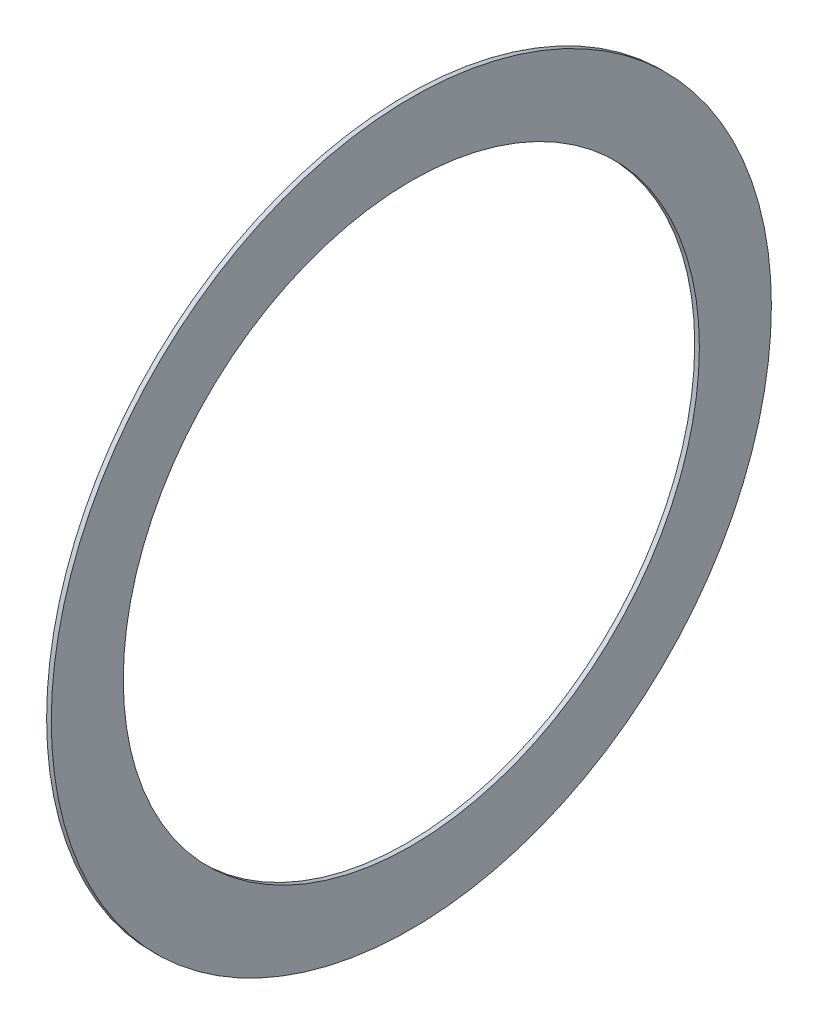
from build123d import *

# Parameters (mm, degrees)
SKETCH1_R           = 155
SKETCH1_R_2         = 124
BOSS_EXTRUDE1_DEPTH = 2


with BuildPart() as part:
    # Sketch1 → Boss-Extrude1 (new body)
    with BuildSketch(Plane(origin=(0, 0, 0), x_dir=(0, 0, -1), z_dir=(1, 0, 0))):
        Circle(SKETCH1_R)
        Circle(SKETCH1_R_2, mode=Mode.SUBTRACT)
    extrude(amount=BOSS_EXTRUDE1_DEPTH)


solid = part.part
